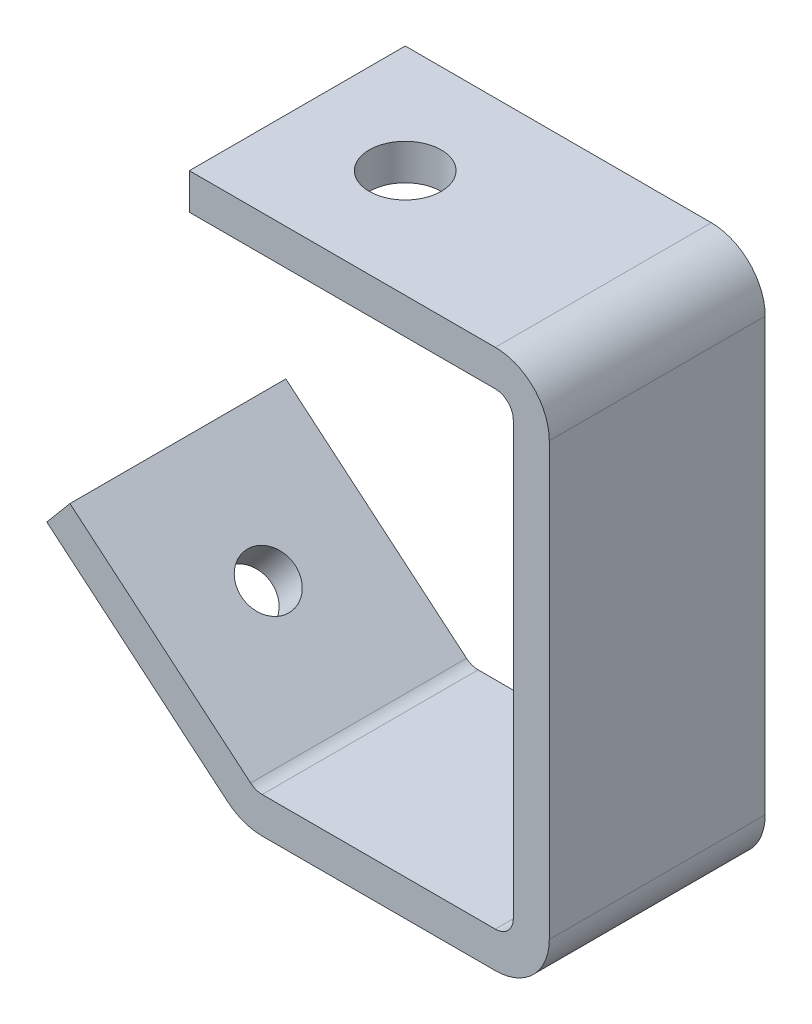
from build123d import *

# Parameters (mm, degrees)
EXTRUDE_THIN1_DEPTH        = 38.1
F_10_0MM_DOWEL_HOLE1_D     = 12.7
F_10_0MM_DOWEL_HOLE1_DEPTH = 6.35
F_10_0MM_DOWEL_HOLE1_TIP   = 3.815464931
F_10_0MM_DOWEL_HOLE2_D     = 9.53
F_10_0MM_DOWEL_HOLE2_DEPTH = 6.35
F_10_0MM_DOWEL_HOLE2_TIP   = 2.86310085


with BuildPart() as part:
    # Sketch1 → Extrude-Thin1 (new body)
    with BuildSketch(Plane.XY):
        with BuildLine():
            Line((-63.51, 47.625), (-9.52, 47.625))
            ThreePointArc((-9.52, 47.625), (-2.788343443, 44.836656557), (0, 38.105))
            Line((0, 38.105), (0, -38.105))
            ThreePointArc((0, -38.105), (-2.788343443, -44.836656557), (-9.52, -47.625))
            Line((-9.52, -47.625), (-50.651363667, -47.625))
            ThreePointArc((-50.651363667, -47.625), (-53.910815633, -47.050270676), (-56.777129588, -45.395403543))
            Line((-56.777129588, -45.395403543), (-88.66094394, -18.641706679))
            Line((-88.66094394, -18.641706679), (-84.579242619, -13.777324465))
            Line((-84.579242619, -13.777324465), (-52.695428266, -40.531021329))
            ThreePointArc((-52.695428266, -40.531021329), (-51.738987723, -41.083222534), (-50.651363667, -41.275))
            Line((-50.651363667, -41.275), (-9.52, -41.275))
            ThreePointArc((-9.52, -41.275), (-7.278471504, -40.346528496), (-6.35, -38.105))
            Line((-6.35, -38.105), (-6.35, 38.105))
            ThreePointArc((-6.35, 38.105), (-7.278471504, 40.346528496), (-9.52, 41.275))
            Line((-9.52, 41.275), (-63.51, 41.275))
            Line((-63.51, 41.275), (-63.51, 47.625))
        make_face()
    extrude(amount=EXTRUDE_THIN1_DEPTH)

    # Ø10.0mm Dowel Hole1
    with Locations(Plane(origin=(0, 47.625, 0), x_dir=(1, 0, 0), z_dir=(0, 1, 0))):
        with Locations((-44.47, -19.05)):
            Hole(F_10_0MM_DOWEL_HOLE1_D / 2, depth=F_10_0MM_DOWEL_HOLE1_DEPTH)
            with Locations((0, 0, -(F_10_0MM_DOWEL_HOLE1_DEPTH + F_10_0MM_DOWEL_HOLE1_TIP / 2))):  # 118° drill point
                Cone(0, F_10_0MM_DOWEL_HOLE1_D / 2, F_10_0MM_DOWEL_HOLE1_TIP, mode=Mode.SUBTRACT)

    # Ø10.0mm Dowel Hole2
    with Locations(Plane(origin=(-45.811814931, -54.596395027, 0), x_dir=(-0.766044443, 0.64278761, 0), z_dir=(-0.64278761, -0.766044443, 0))):
        with Locations((35.12556535, -19.05)):
            Hole(F_10_0MM_DOWEL_HOLE2_D / 2, depth=F_10_0MM_DOWEL_HOLE2_DEPTH)
            with Locations((0, 0, -(F_10_0MM_DOWEL_HOLE2_DEPTH + F_10_0MM_DOWEL_HOLE2_TIP / 2))):  # 118° drill point
                Cone(0, F_10_0MM_DOWEL_HOLE2_D / 2, F_10_0MM_DOWEL_HOLE2_TIP, mode=Mode.SUBTRACT)


solid = part.part
